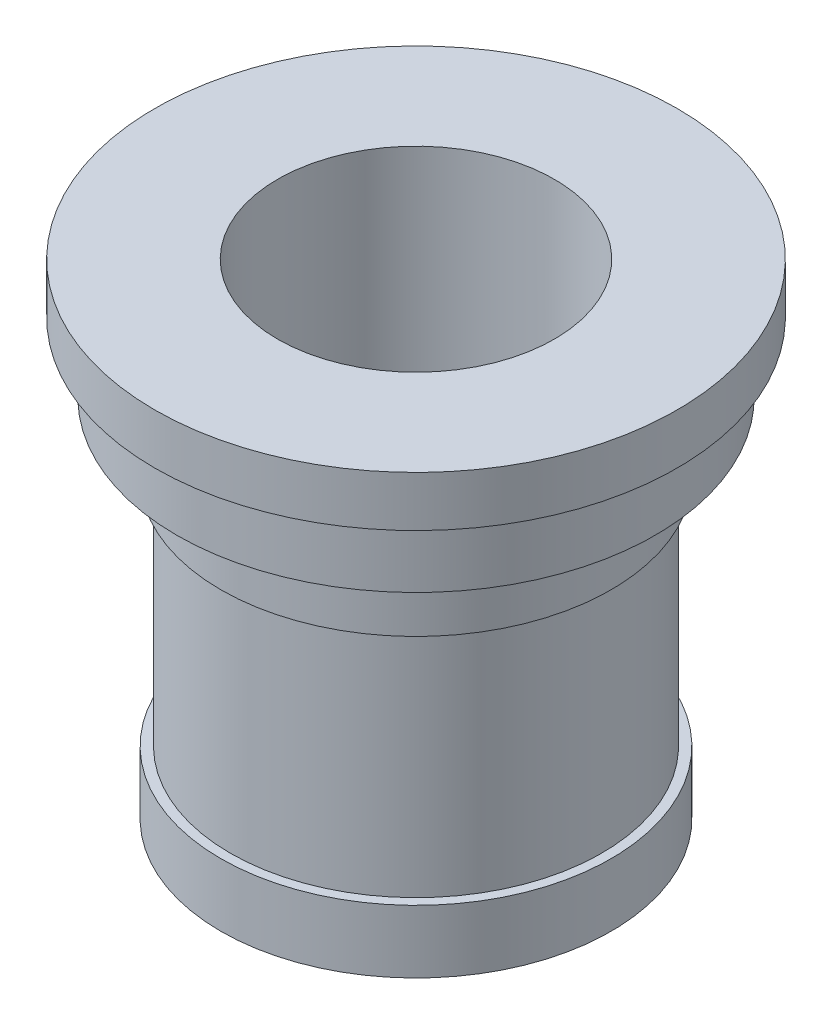
from build123d import *

# Parameters (mm, degrees)
SKETCH4_R          = 22
CUT_EXTRUDE1_DEPTH = 78
SKETCH5_R          = 1.5
CUT_EXTRUDE2_DEPTH = 10


with BuildPart() as part:
    # Sketch3 → Revolve1 (revolve)
    with BuildSketch(Plane.XY, mode=Mode.PRIVATE) as revolve1_sk:
        Polygon((0, 0), (31, 0), (31, 10), (29.5, 10), (29.5, 47), (31, 47), (31, 58), (38, 58), (38, 69), (41.5, 69), (41.5, 77), (0, 77), align=None)
    revolve(revolve1_sk.sketch.rotate(Axis((0, 98.317518248, 0), (0, -1, 0)), 90), axis=Axis((0, 98.317518248, 0), (0, -1, 0)))  # turned: the seam where the file's is

    # Sketch4 → Cut-Extrude1 (cut, through all)
    with BuildSketch(Plane(origin=(0, 77, 0), x_dir=(1, 0, 0), z_dir=(0, 1, 0))):
        with Locations(Location((0, 0, 0), (0, 0, 270))):  # turned: the seam where the file's is
            Circle(SKETCH4_R)
    extrude(amount=-CUT_EXTRUDE1_DEPTH, mode=Mode.SUBTRACT)

    # Sketch5 → Cut-Extrude2 (cut)
    with BuildSketch(Plane(origin=(0, 0, 0), x_dir=(-1, 0, 0), z_dir=(0, -1, 0))):
        with Locations((0, 22)):
            Circle(SKETCH5_R)
    extrude(amount=-CUT_EXTRUDE2_DEPTH, mode=Mode.SUBTRACT)


solid = part.part
